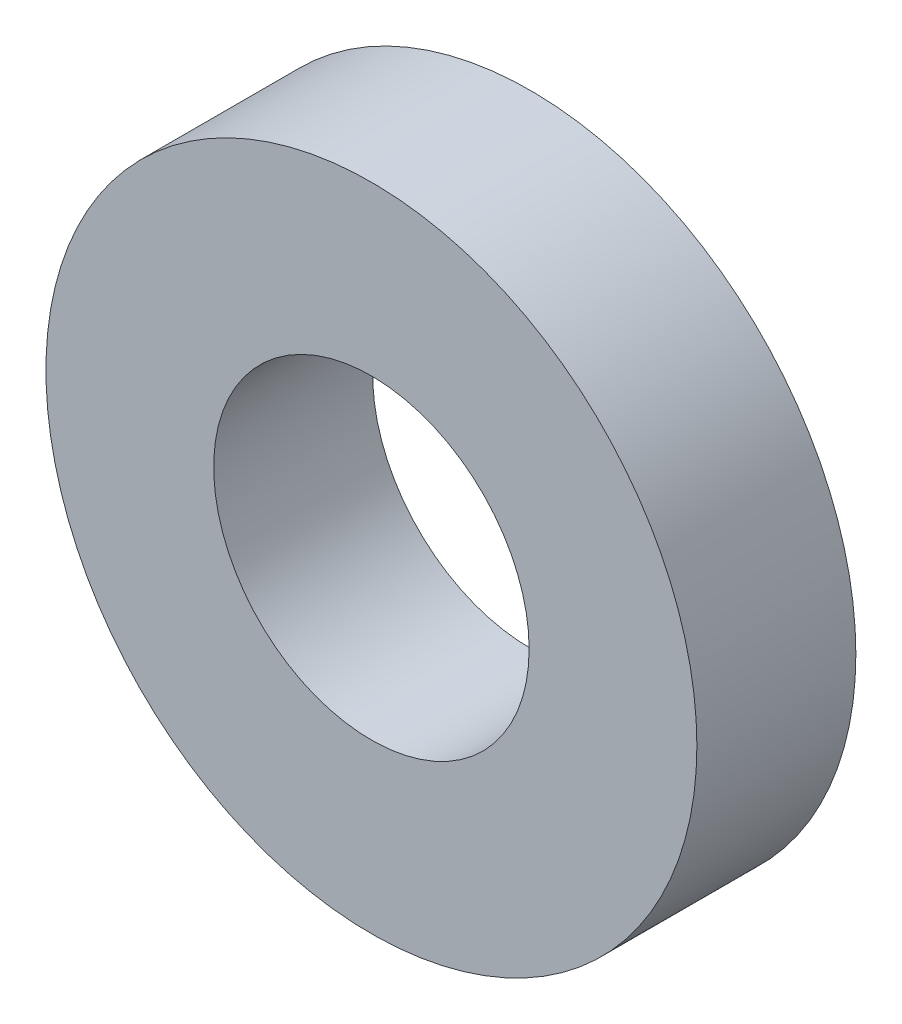
from build123d import *

# Parameters (mm, degrees)
SKETCH1_R      = 6.5
SKETCH1_R_2    = 3.15
EXTRUDE1_DEPTH = 1.5875


with BuildPart() as part:
    # Sketch1 → Extrude1 (new body, symmetric)
    with BuildSketch(Plane.XY):
        Circle(SKETCH1_R)
        Circle(SKETCH1_R_2, mode=Mode.SUBTRACT)
    extrude(amount=EXTRUDE1_DEPTH, both=True)


solid = part.part
